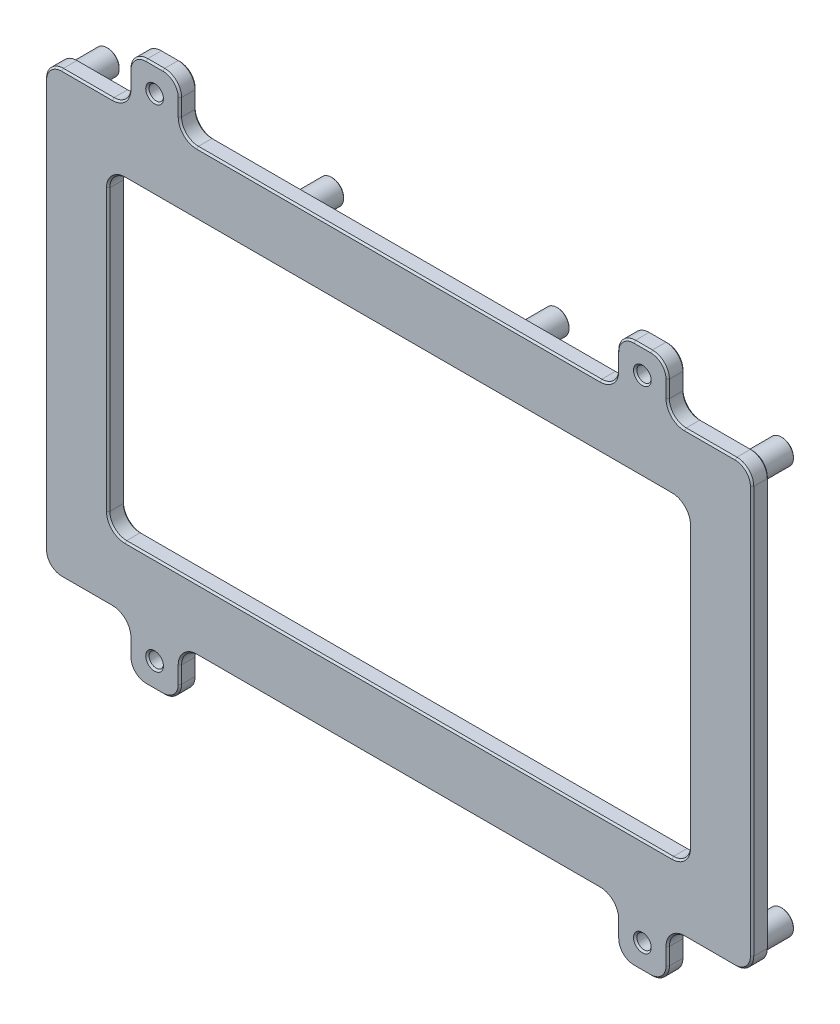
from build123d import *

# Parameters (mm, degrees)
SKETCH1_W               = 167.6
SKETCH1_H               = 104.425
SKETCH1_W_2             = 137.6
SKETCH1_H_2             = 74.425
BOSS_EXTRUDE1_DEPTH     = 4
SKETCH2_R               = 2.9125
SKETCH2_R_2             = 0.9125
BOSS_EXTRUDE2_DEPTH     = 7
SKETCH1_5_W             = 12
SKETCH1_5_H             = 12
SKETCH1_5_R             = 1.7
BOSS_EXTRUDE3_DEPTH     = 4
MIRROR2_COPY_1_SKETCH_W = 12
MIRROR2_COPY_1_SKETCH_H = 12
MIRROR2_COPY_1_SKETCH_R = 1.7
MIRROR2_COPY_1_DEPTH    = 4
FILLET1_R               = 4
CHAMFER1_SIZE           = 0.4
CHAMFER2_SIZE           = 0.2


with BuildPart() as part:
    # Sketch1 → Boss-Extrude1 (new body)
    with BuildSketch(Plane.XY):
        with Locations((-7.949197716, 6.523583189)):
            Rectangle(SKETCH1_W, SKETCH1_H)
        with Locations((-7.949197716, 6.523583189)):
            Rectangle(SKETCH1_W_2, SKETCH1_H_2, mode=Mode.SUBTRACT)
    extrude(amount=BOSS_EXTRUDE1_DEPTH)

    # Sketch2 → Boss-Extrude2 (add)
    with BuildSketch(Plane(origin=(0, 0, 0), x_dir=(-1, 0, 0), z_dir=(0, 0, -1))):
        with Locations((87.836697716, -41.776416811)):
            Circle(SKETCH2_R)
        with Locations((87.836697716, -41.776416811)):
            Circle(SKETCH2_R_2, mode=Mode.SUBTRACT)
        with Locations((34.661697716, -41.776416811)):
            Circle(SKETCH2_R)
        with Locations((34.661697716, -41.776416811)):
            Circle(SKETCH2_R_2, mode=Mode.SUBTRACT)
        with Locations((-18.763302284, -41.776416811)):
            Circle(SKETCH2_R)
        with Locations((-18.763302284, -41.776416811)):
            Circle(SKETCH2_R_2, mode=Mode.SUBTRACT)
        with Locations((-71.938302284, -41.776416811)):
            Circle(SKETCH2_R)
        with Locations((-71.938302284, -41.776416811)):
            Circle(SKETCH2_R_2, mode=Mode.SUBTRACT)
        with Locations((-71.938302284, 54.823583189)):
            Circle(SKETCH2_R)
        with Locations((-71.938302284, 54.823583189)):
            Circle(SKETCH2_R_2, mode=Mode.SUBTRACT)
        with Locations((-18.763302284, 54.823583189)):
            Circle(SKETCH2_R)
        with Locations((-18.763302284, 54.823583189)):
            Circle(SKETCH2_R_2, mode=Mode.SUBTRACT)
        with Locations((34.661697716, 54.823583189)):
            Circle(SKETCH2_R)
        with Locations((34.661697716, 54.823583189)):
            Circle(SKETCH2_R_2, mode=Mode.SUBTRACT)
        with Locations((87.836697716, 54.823583189)):
            Circle(SKETCH2_R)
        with Locations((87.836697716, 54.823583189)):
            Circle(SKETCH2_R_2, mode=Mode.SUBTRACT)
    extrude(amount=BOSS_EXTRUDE2_DEPTH)

    # Sketch1_5 → Boss-Extrude3 (add)
    with BuildSketch(Plane.XY):
        with Locations((49.850802284, 64.736083189)):
            Rectangle(SKETCH1_5_W, SKETCH1_5_H)
        with Locations((49.850802284, 64.736083189)):
            Circle(SKETCH1_5_R, mode=Mode.SUBTRACT)
    boss_extrude3 = extrude(amount=BOSS_EXTRUDE3_DEPTH)

    # Mirror1: Boss-Extrude3 across plane
    add(boss_extrude3.mirror(Plane(origin=(-7.949197716, 0, 0), x_dir=(0, 0, 1), z_dir=(1, 0, 0))))

    # Mirror2: Boss-Extrude3 across plane
    add(boss_extrude3.mirror(Plane.ZX.offset(6.523583189)))

    # Mirror2 copy 1 sketch → Mirror2 copy 1 (add)
    with BuildSketch(Plane(origin=(-15.898395433, 13.047166377, 0), x_dir=(-1, 0, 0), z_dir=(0, 0, 1))):
        with Locations((49.850802284, 64.736083189)):
            Rectangle(MIRROR2_COPY_1_SKETCH_W, MIRROR2_COPY_1_SKETCH_H)
        with Locations((49.850802284, 64.736083189)):
            Circle(MIRROR2_COPY_1_SKETCH_R, mode=Mode.SUBTRACT)
    extrude(amount=MIRROR2_COPY_1_DEPTH)

    # Fillet1
    fillet1_edges = [part.edges().sort_by_distance(p)[0] for p in [
        (-59.749197716, -45.688916811, 2),
        (-71.749197716, -45.688916811, 2),
        (-71.749197716, -57.688916811, 2),
        (-59.749197716, -57.688916811, 2),
        (55.850802284, -57.688916811, 2),
        (43.850802284, -57.688916811, 2),
        (43.850802284, -45.688916811, 2),
        (55.850802284, -45.688916811, 2),
        (60.850802284, -30.688916811, 2),
        (60.850802284, 43.736083189, 2),
        (-76.749197716, 43.736083189, 2),
        (-76.749197716, -30.688916811, 2),
        (-91.749197716, -45.688916811, 2),
        (75.850802284, -45.688916811, 2),
        (75.850802284, 58.736083189, 2),
        (-91.749197716, 58.736083189, 2),
        (43.850802284, 58.736083189, 2),
        (55.850802284, 58.736083189, 2),
        (55.850802284, 70.736083189, 2),
        (43.850802284, 70.736083189, 2),
        (-71.749197716, 70.736083189, 2),
        (-59.749197716, 70.736083189, 2),
        (-59.749197716, 58.736083189, 2),
        (-71.749197716, 58.736083189, 2),
    ]]
    fillet(fillet1_edges, radius=FILLET1_R)

    # Chamfer1
    chamfer1_edges = [part.edges().sort_by_distance(p)[0] for p in [
        (-64.049197716, -51.688916811, 0),
        (-64.049197716, -51.688916811, 4),
        (48.150802284, -51.688916811, 4),
        (48.150802284, -51.688916811, 0),
        (-7.949197716, -30.688916811, 0),
        (-7.949197716, -30.688916811, 4),
        (60.850802284, 6.523583189, 0),
        (60.850802284, 6.523583189, 4),
        (-7.949197716, 43.736083189, 0),
        (-7.949197716, 43.736083189, 4),
        (-76.749197716, 6.523583189, 0),
        (-76.749197716, 6.523583189, 4),
        (-65.749197716, 70.736083189, 4),
        (-65.749197716, 70.736083189, 0),
        (-91.749197716, 6.523583189, 0),
        (-81.749197716, 58.736083189, 0),
        (-71.749197716, 64.736083189, 0),
        (-59.749197716, 64.736083189, 0),
        (-7.949197716, 58.736083189, 0),
        (43.850802284, 64.736083189, 0),
        (49.850802284, 70.736083189, 0),
        (55.850802284, 64.736083189, 0),
        (65.850802284, 58.736083189, 0),
        (75.850802284, 6.523583189, 0),
        (65.850802284, -45.688916811, 0),
        (55.850802284, -51.688916811, 0),
        (49.850802284, -57.688916811, 0),
        (43.850802284, -51.688916811, 0),
        (-7.949197716, -45.688916811, 0),
        (-59.749197716, -51.688916811, 0),
        (-65.749197716, -57.688916811, 0),
        (-71.749197716, -51.688916811, 0),
        (-81.749197716, -45.688916811, 0),
        (54.679229408, 69.564510313, 0),
        (45.022375159, 69.564510313, 0),
        (74.679229408, 57.564510313, 0),
        (74.679229408, -44.517343936, 0),
        (54.679229408, -56.517343936, 0),
        (45.022375159, -56.517343936, 0),
        (-60.920770592, -56.517343936, 0),
        (-70.577624841, -56.517343936, 0),
        (-90.577624841, -44.517343936, 0),
        (-90.577624841, 57.564510313, 0),
        (-70.577624841, 69.564510313, 0),
        (-60.920770592, 69.564510313, 0),
        (-59.749197716, 64.736083189, 4),
        (-91.749197716, 6.523583189, 4),
        (-81.749197716, -45.688916811, 4),
        (-71.749197716, -51.688916811, 4),
        (-65.749197716, -57.688916811, 4),
        (-59.749197716, -51.688916811, 4),
        (-7.949197716, -45.688916811, 4),
        (43.850802284, -51.688916811, 4),
        (49.850802284, -57.688916811, 4),
        (55.850802284, -51.688916811, 4),
        (65.850802284, -45.688916811, 4),
        (75.850802284, 6.523583189, 4),
        (65.850802284, 58.736083189, 4),
        (55.850802284, 64.736083189, 4),
        (49.850802284, 70.736083189, 4),
        (43.850802284, 64.736083189, 4),
        (-7.949197716, 58.736083189, 4),
        (-71.749197716, 64.736083189, 4),
        (-81.749197716, 58.736083189, 4),
        (54.679229408, 69.564510313, 4),
        (45.022375159, 69.564510313, 4),
        (74.679229408, 57.564510313, 4),
        (74.679229408, -44.517343936, 4),
        (54.679229408, -56.517343936, 4),
        (45.022375159, -56.517343936, 4),
        (-60.920770592, -56.517343936, 4),
        (-70.577624841, -56.517343936, 4),
        (-90.577624841, -44.517343936, 4),
        (-90.577624841, 57.564510313, 4),
        (-70.577624841, 69.564510313, 4),
        (-60.920770592, 69.564510313, 4),
        (59.679229408, -29.517343936, 0),
        (59.679229408, -29.517343936, 4),
        (59.679229408, 42.564510313, 0),
        (59.679229408, 42.564510313, 4),
        (-75.577624841, 42.564510313, 0),
        (-75.577624841, 42.564510313, 4),
        (-75.577624841, -29.517343936, 0),
        (-75.577624841, -29.517343936, 4),
        (-58.577624841, 59.907656064, 0),
        (-58.577624841, 59.907656064, 4),
        (-72.920770592, 59.907656064, 0),
        (-72.920770592, 59.907656064, 4),
        (-72.920770592, -46.860489687, 0),
        (-72.920770592, -46.860489687, 4),
        (-58.577624841, -46.860489687, 0),
        (-58.577624841, -46.860489687, 4),
        (42.679229408, -46.860489687, 0),
        (42.679229408, -46.860489687, 4),
        (57.022375159, -46.860489687, 0),
        (57.022375159, -46.860489687, 4),
        (42.679229408, 59.907656064, 0),
        (42.679229408, 59.907656064, 4),
        (57.022375159, 59.907656064, 0),
        (57.022375159, 59.907656064, 4),
        (-84.924197716, -41.776416811, 0),
        (-31.749197716, -41.776416811, 0),
        (21.675802284, -41.776416811, 0),
        (74.850802284, -41.776416811, 0),
        (74.850802284, 54.823583189, 0),
        (21.675802284, 54.823583189, 0),
        (-31.749197716, 54.823583189, 0),
        (-84.924197716, 54.823583189, 0),
        (48.150802284, 64.736083189, 0),
        (48.150802284, 64.736083189, 4),
        (-64.049197716, 64.736083189, 4),
        (-64.049197716, 64.736083189, 0),
    ]]
    chamfer(chamfer1_edges, length=CHAMFER1_SIZE)

    # Chamfer2
    chamfer2_edges = [part.edges().sort_by_distance(p)[0] for p in [
        (-84.924197716, -41.776416811, -7),
        (-86.924197716, -41.776416811, -7),
        (-31.749197716, -41.776416811, -7),
        (-33.749197716, -41.776416811, -7),
        (21.675802284, -41.776416811, -7),
        (19.675802284, -41.776416811, -7),
        (74.850802284, -41.776416811, -7),
        (72.850802284, -41.776416811, -7),
        (74.850802284, 54.823583189, -7),
        (72.850802284, 54.823583189, -7),
        (21.675802284, 54.823583189, -7),
        (19.675802284, 54.823583189, -7),
        (-31.749197716, 54.823583189, -7),
        (-33.749197716, 54.823583189, -7),
        (-84.924197716, 54.823583189, -7),
        (-86.924197716, 54.823583189, -7),
    ]]
    chamfer(chamfer2_edges, length=CHAMFER2_SIZE)


solid = part.part
